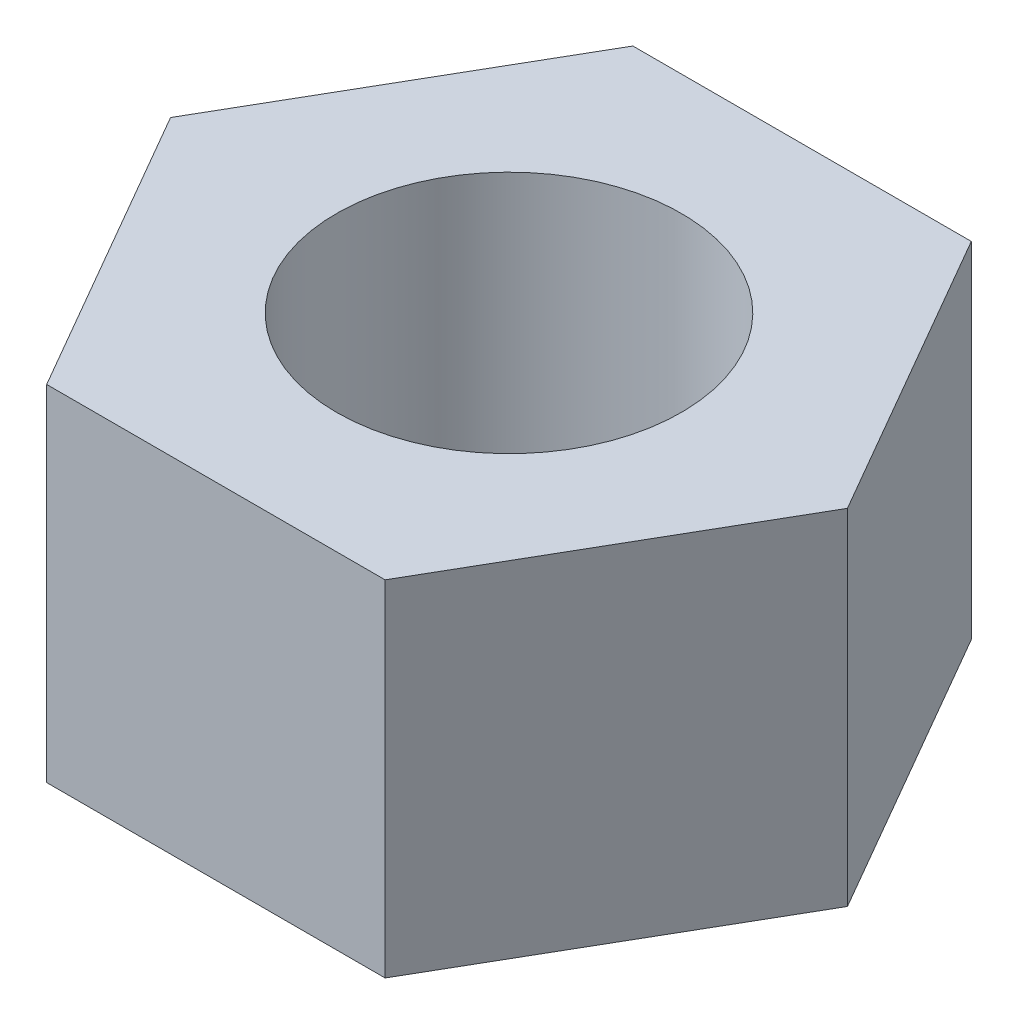
from build123d import *

# Parameters (mm, degrees)
SKETCH1_R           = 5
BOSS_EXTRUDE1_DEPTH = 5


with BuildPart() as part:
    # Sketch1 → Boss-Extrude1 (new body, symmetric)
    with BuildSketch(Plane(origin=(0, 0, 0), x_dir=(1, 0, 0), z_dir=(0, 1, 0))):
        Polygon((9.814954576, 0), (4.907477288, 8.5), (-4.907477288, 8.5), (-9.814954576, 0), (-4.907477288, -8.5), (4.907477288, -8.5), align=None)
        Circle(SKETCH1_R, mode=Mode.SUBTRACT)
    extrude(amount=BOSS_EXTRUDE1_DEPTH, both=True)


solid = part.part
